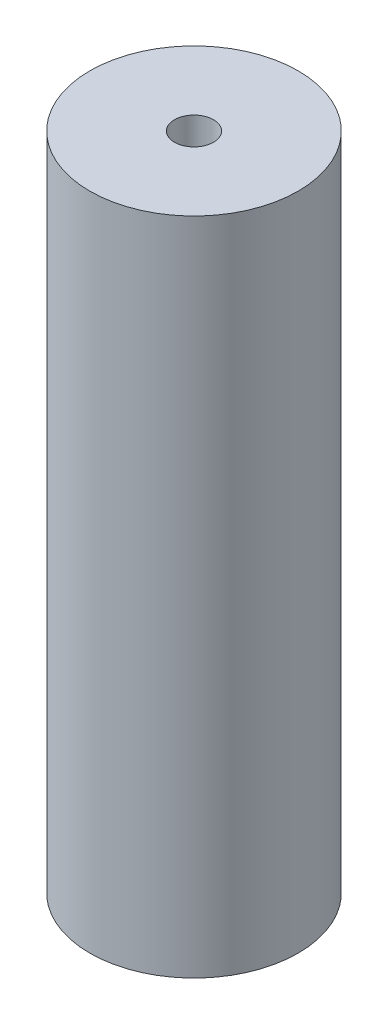
from build123d import *

# Parameters (mm, degrees)
SKIZZE1_R                       = 6
AUFSATZ_LINEAR_AUSTRAGEN1_DEPTH = 38
SKIZZE2_R                       = 1.125
SCHNITT_LINEAR_AUSTRAGEN1_DEPTH = 39
SKIZZE3_R                       = 2.75
SCHNITT_LINEAR_AUSTRAGEN2_DEPTH = 21


with BuildPart() as part:
    # Skizze1 → Aufsatz-Linear austragen1 (new body)
    with BuildSketch(Plane(origin=(0, 0, 0), x_dir=(1, 0, 0), z_dir=(0, 1, 0))):
        Circle(SKIZZE1_R)
    extrude(amount=AUFSATZ_LINEAR_AUSTRAGEN1_DEPTH)

    # Skizze2 → Schnitt-Linear austragen1 (cut, through all)
    with BuildSketch(Plane(origin=(0, 0, 0), x_dir=(-1, 0, 0), z_dir=(0, -1, 0))):
        Circle(SKIZZE2_R)
    extrude(amount=-SCHNITT_LINEAR_AUSTRAGEN1_DEPTH, mode=Mode.SUBTRACT)

    # Skizze3 → Schnitt-Linear austragen2 (cut)
    with BuildSketch(Plane(origin=(0, 0, 0), x_dir=(-1, 0, 0), z_dir=(0, -1, 0))):
        Circle(SKIZZE3_R)
    extrude(amount=-SCHNITT_LINEAR_AUSTRAGEN2_DEPTH, mode=Mode.SUBTRACT)


solid = part.part
